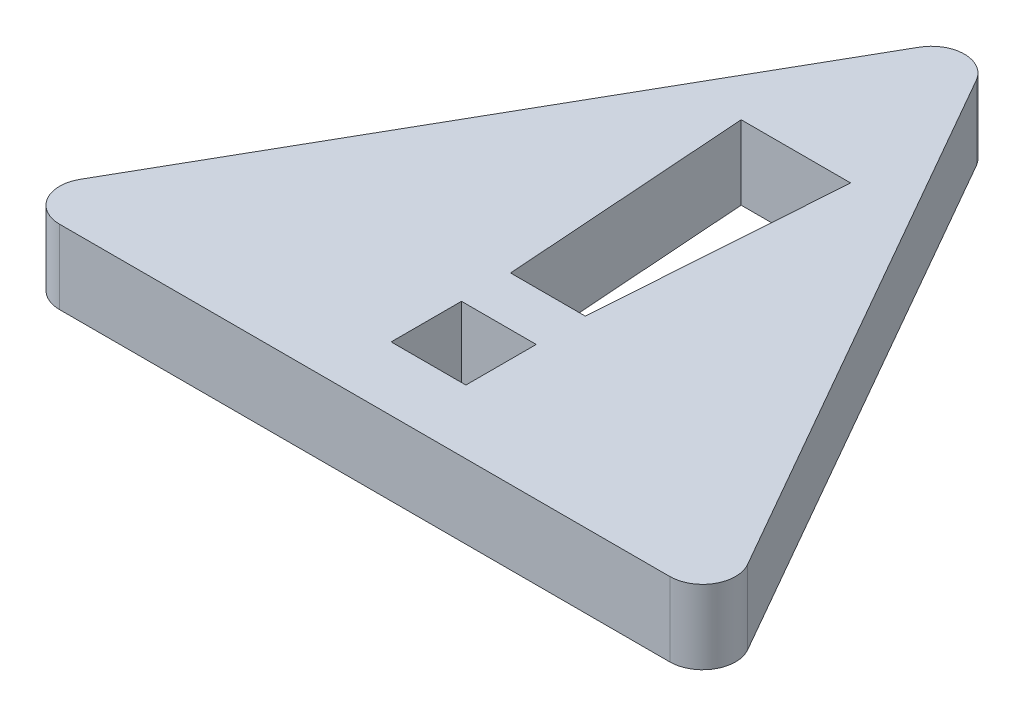
from build123d import *

# Parameters (mm, degrees)
SKETCH1_W           = 2.272369049
SKETCH1_H           = 2.138700281
BOSS_EXTRUDE1_DEPTH = 2.25
FILLET1_R           = 1


with BuildPart() as part:
    # Sketch1 → Boss-Extrude1 (new body)
    with BuildSketch(Plane(origin=(0, 0, 0), x_dir=(1, 0, 0), z_dir=(0, 1, 0))):
        Polygon((-17.128579952, 1.837543865), (-6.128579952, 21.087543865), (4.871420048, 1.837543865), align=None)
        Polygon((-7.264764476, 7.408947213), (-4.992395427, 7.408947213), (-4.463947201, 14.949533453), (-7.793212702, 14.949533453), align=None, mode=Mode.SUBTRACT)
        with Locations((-6.128579952, 4.848079389)):
            Rectangle(SKETCH1_W, SKETCH1_H, mode=Mode.SUBTRACT)
    extrude(amount=BOSS_EXTRUDE1_DEPTH)

    # Fillet1
    fillet1_edges = [part.edges().sort_by_distance(p)[0] for p in [
        (-17.128579952, 1.125, -1.837543865),
        (-6.128579952, 1.125, -21.087543865),
        (4.871420048, 1.125, -1.837543865),
    ]]
    fillet(fillet1_edges, radius=FILLET1_R)


solid = part.part
